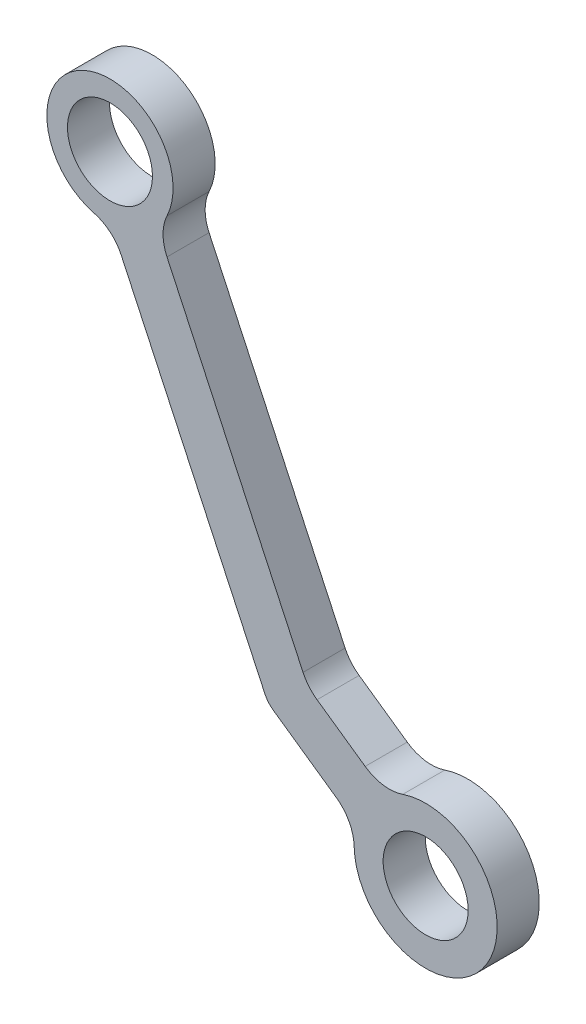
from build123d import *

# Parameters (mm, degrees)
ESQUISSE2_R        = 6.4135
BOSS_EXTRU_1_DEPTH = 6.35


with BuildPart() as part:
    # Esquisse2 → Boss.-Extru.1 (new body)
    with BuildSketch(Plane(origin=(-37.908707754, 0, 1.245941937), x_dir=(1, 0, 0), z_dir=(0, 0, 1))):
        with BuildLine():
            Line((39.610752218, -12.665274164), (61.291934706, -59.160720054))
            ThreePointArc((61.291934706, -59.160720054), (61.826338046, -59.99956527), (62.559641152, -60.671513766))
            Line((62.559641152, -60.671513766), (72.053336788, -67.319071016))
            ThreePointArc((72.053336788, -67.319071016), (74.008942258, -69.522860983), (74.759386744, -72.372056668))
            ThreePointArc((74.759386744, -72.372056668), (94.394175617, -78.311143591), (82.097766158, -61.891764736))
            ThreePointArc((82.097766158, -61.891764736), (79.163730867, -62.161059907), (76.423989233, -61.077132438))
            Line((76.423989233, -61.077132438), (69.160323465, -55.991058912))
            ThreePointArc((69.160323465, -55.991058912), (67.938151622, -54.871144752), (67.047479388, -53.473069393))
            Line((67.047479388, -53.473069393), (46.516817555, -9.444923009))
            ThreePointArc((46.516817555, -9.444923009), (45.921882482, -6.749760897), (46.526606303, -4.056778228))
            ThreePointArc((46.526606303, -4.056778228), (33.883268811, 8.632581672), (35.476901763, -9.209340075))
            ThreePointArc((35.476901763, -9.209340075), (37.928555152, -10.477110645), (39.610752218, -12.665274164))
        make_face()
        with Locations((37.908707754, 0)):
            Circle(ESQUISSE2_R, mode=Mode.SUBTRACT)
        with Locations((85.551429299, -72.11938596)):
            Circle(ESQUISSE2_R, mode=Mode.SUBTRACT)
    extrude(amount=BOSS_EXTRU_1_DEPTH)


solid = part.part
